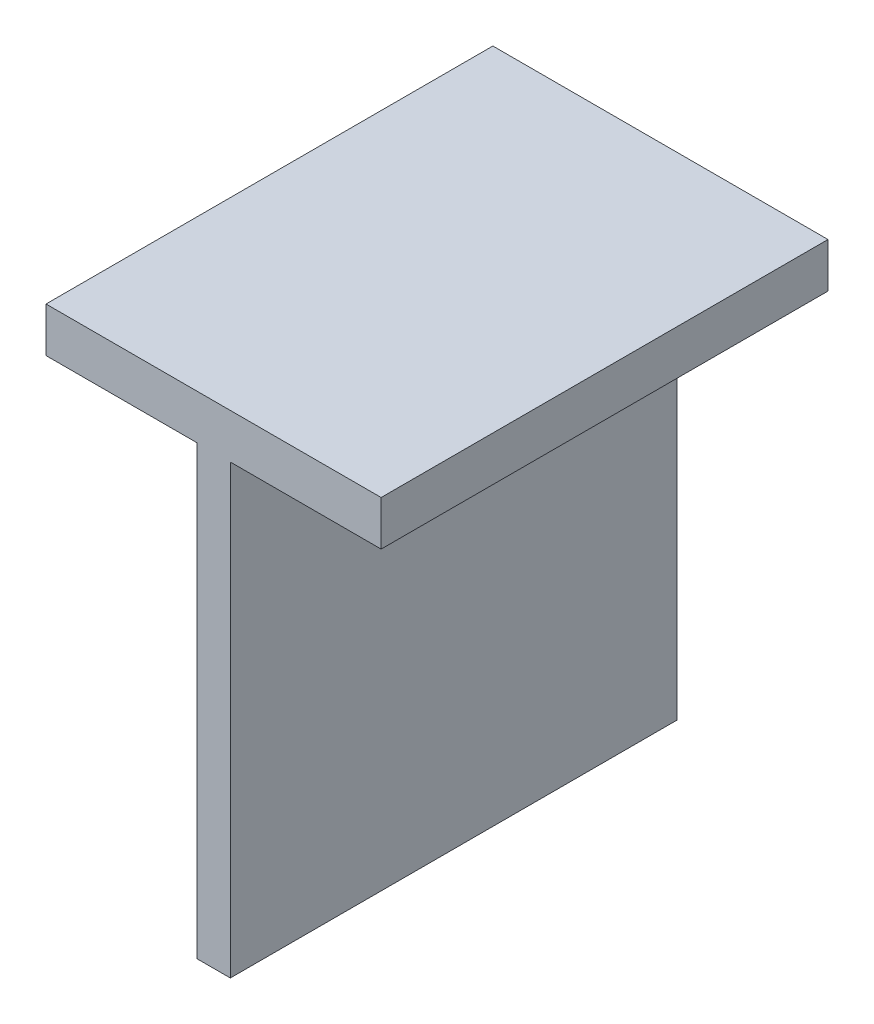
from build123d import *

# Parameters (mm, degrees)
BOSS_EXTRUDE1_DEPTH = 2000


with BuildPart() as part:
    # Sketch1 → Boss-Extrude1 (new body)
    with BuildSketch(Plane.XY):
        Polygon((75, 0), (75, 2000), (750, 2000), (750, 2200), (-750, 2200), (-750, 2000), (-75, 2000), (-75, 0), align=None)
    extrude(amount=BOSS_EXTRUDE1_DEPTH)


solid = part.part
